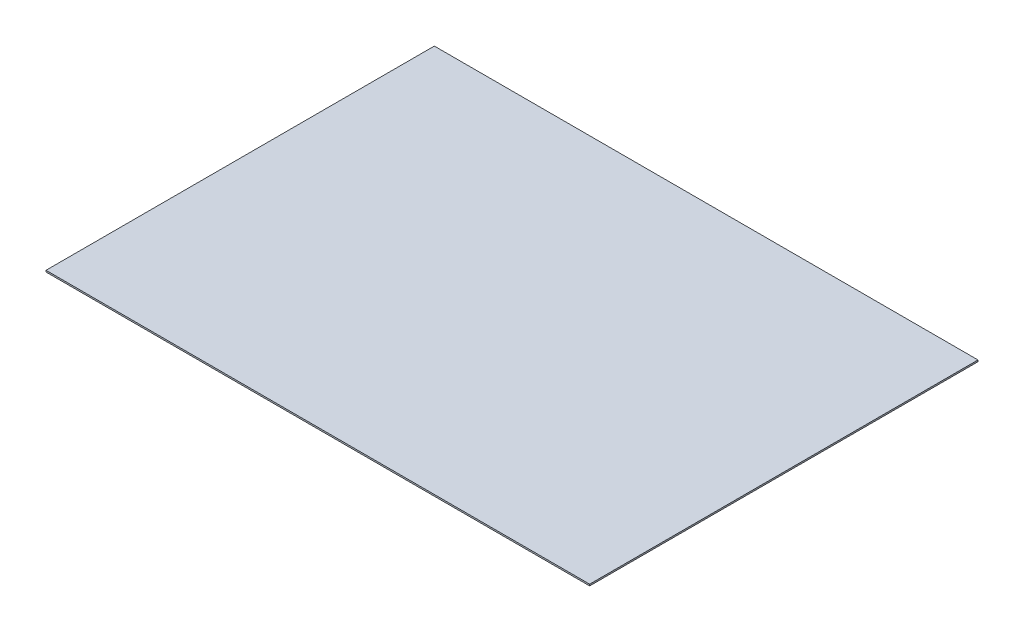
from build123d import *

# Parameters (mm, degrees)
SKETCH1_W           = 700
SKETCH1_H           = 500
BOSS_EXTRUDE1_DEPTH = 2


with BuildPart() as part:
    # Sketch1 → Boss-Extrude1 (new body)
    with BuildSketch(Plane(origin=(0, 0, 0), x_dir=(1, 0, 0), z_dir=(0, 1, 0))):
        Rectangle(SKETCH1_W, SKETCH1_H)
    extrude(amount=BOSS_EXTRUDE1_DEPTH)


solid = part.part
